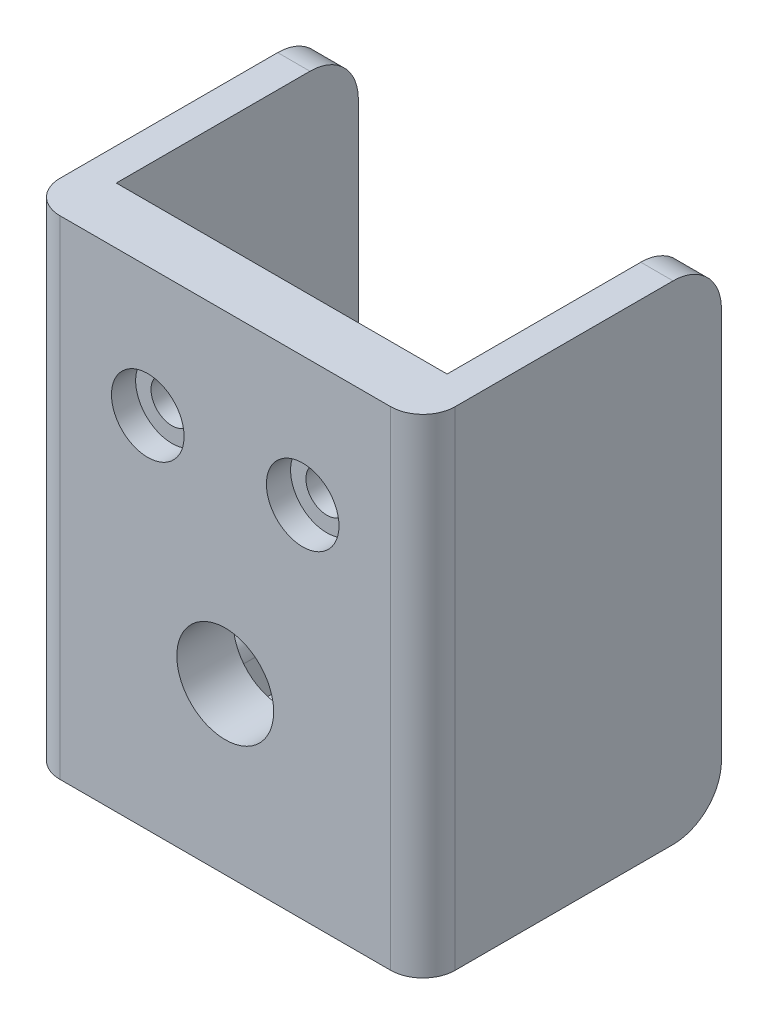
from build123d import *

# Parameters (mm, degrees)
SKETCH1_W           = 20.5
SKETCH1_H           = 30.25
SKETCH1_R           = 1.3
SKETCH1_R_2         = 3
BOSS_EXTRUDE1_DEPTH = 3.5
SKETCH2_W           = 2
SKETCH2_H           = 18.5
BOSS_EXTRUDE2_DEPTH = 30.25
SKETCH3_W           = 6.5
SKETCH3_H           = 10.5
BOSS_EXTRUDE3_DEPTH = 2
FILLET1_R           = 3.5
FILLET2_R           = 2
SKETCH4_R           = 2.25
CUT_EXTRUDE1_DEPTH  = 1.5
FILLET4_R           = 3
SKETCH9_W           = 4
SKETCH9_H           = 4
BOSS_EXTRUDE4_DEPTH = 6.5
FILLET6_R           = 1.5
BOSS_EXTRUDE5_DEPTH = 2
BOSS_EXTRUDE6_DEPTH = 1


with BuildPart() as part:
    # Sketch1 → Boss-Extrude1 (new body)
    with BuildSketch(Plane.XY):
        with Locations((0, -2.125)):
            Rectangle(SKETCH1_W, SKETCH1_H)
        with Locations((-4.8, 5)):
            Circle(SKETCH1_R, mode=Mode.SUBTRACT)
        with Locations((4.8, 5)):
            Circle(SKETCH1_R, mode=Mode.SUBTRACT)
        with Locations((0, -7)):
            Circle(SKETCH1_R_2, mode=Mode.SUBTRACT)
    extrude(amount=BOSS_EXTRUDE1_DEPTH)

    # Sketch2 → Boss-Extrude2 (add)
    with BuildSketch(Plane(origin=(0, -17.25, 0), x_dir=(-1, 0, 0), z_dir=(0, -1, 0))):
        with Locations((11.25, 5.75)):
            Rectangle(SKETCH2_W, SKETCH2_H)
        with Locations((-11.25, 5.75)):
            Rectangle(SKETCH2_W, SKETCH2_H)
    extrude(amount=-BOSS_EXTRUDE2_DEPTH)

    # Sketch3 → Boss-Extrude3 (add)
    with BuildSketch(Plane.XZ.offset(17.25)):
        with Locations((-7, -5.25)):
            Rectangle(SKETCH3_W, SKETCH3_H)
        with Locations((7, -5.25)):
            Rectangle(SKETCH3_W, SKETCH3_H)
    extrude(amount=-BOSS_EXTRUDE3_DEPTH)

    # Fillet1
    fillet1_edges = [part.edges().sort_by_distance(p)[0] for p in [
        (-3.75, -16.25, 0),
        (3.75, -16.25, 0),
    ]]
    fillet(fillet1_edges, radius=FILLET1_R)

    # Fillet2
    fillet2_edges = [part.edges().sort_by_distance(p)[0] for p in [
        (-12.25, -2.125, 3.5),
        (12.25, -2.125, 3.5),
    ]]
    fillet(fillet2_edges, radius=FILLET2_R)

    # Sketch4 → Cut-Extrude1 (cut)
    with BuildSketch(Plane.XY.offset(3.5)):
        with Locations((-4.8, 5)):
            Circle(SKETCH4_R)
        with Locations((4.8, 5)):
            Circle(SKETCH4_R)
    extrude(amount=-CUT_EXTRUDE1_DEPTH, mode=Mode.SUBTRACT)

    # Fillet4
    fillet4_edges = [part.edges().sort_by_distance(p)[0] for p in [
        (-11.25, 13, -15),
        (-11.25, -17.25, -15),
        (11.25, 13, -15),
        (11.25, -17.25, -15),
    ]]
    fillet(fillet4_edges, radius=FILLET4_R)

    # Sketch9 → Boss-Extrude4 (add)
    with BuildSketch(Plane(origin=(0, 0, 0), x_dir=(-1, 0, 0), z_dir=(0, 0, -1))):
        with Locations((-8.25, -13.25)):
            Rectangle(SKETCH9_W, SKETCH9_H)
        with Locations((8.25, -13.25)):
            Rectangle(SKETCH9_W, SKETCH9_H)
    extrude(amount=BOSS_EXTRUDE4_DEPTH)

    # Fillet6
    fillet6_edges = [part.edges().sort_by_distance(p)[0] for p in [
        (-6.25, -11.25, -3.25),
        (6.25, -11.25, -3.25),
        (-10.25, -16.25, -10.5),
        (10.25, -16.25, -10.5),
        (-3.75, -16.25, -10.5),
        (3.75, -16.25, -10.5),
    ]]
    fillet(fillet6_edges, radius=FILLET6_R)

    # Sketch10 → Boss-Extrude5 (add)
    with BuildSketch(Plane.XZ.offset(17.25)):
        with BuildLine():
            Line((-0.25, 0), (0.25, 0))
            ThreePointArc((0.25, 0), (2.668052064, -0.969580229), (3.746392428, -3.341129019))
            Line((3.746392428, -3.341129019), (1.948302942, -3.341129019))
            ThreePointArc((1.948302942, -3.341129019), (0, -1.545230361), (-1.948302942, -3.341129019))
            Line((-1.948302942, -3.341129019), (-3.746392428, -3.341129019))
            ThreePointArc((-3.746392428, -3.341129019), (-2.668052064, -0.969580229), (-0.25, 0))
        make_face()
    extrude(amount=-BOSS_EXTRUDE5_DEPTH)

    # Sketch11 → Boss-Extrude6 (add)
    with BuildSketch(Plane.XZ.offset(17.25)):
        with BuildLine():
            Line((-1.948302942, -3.341129019), (-3.746392428, -3.341129019))
            ThreePointArc((-3.746392428, -3.341129019), (0, 0.246607561), (3.746392428, -3.341129019))
            Line((3.746392428, -3.341129019), (1.948302942, -3.341129019))
            ThreePointArc((1.948302942, -3.341129019), (0, -1.545230361), (-1.948302942, -3.341129019))
        make_face()
    extrude(amount=BOSS_EXTRUDE6_DEPTH)


solid = part.part
